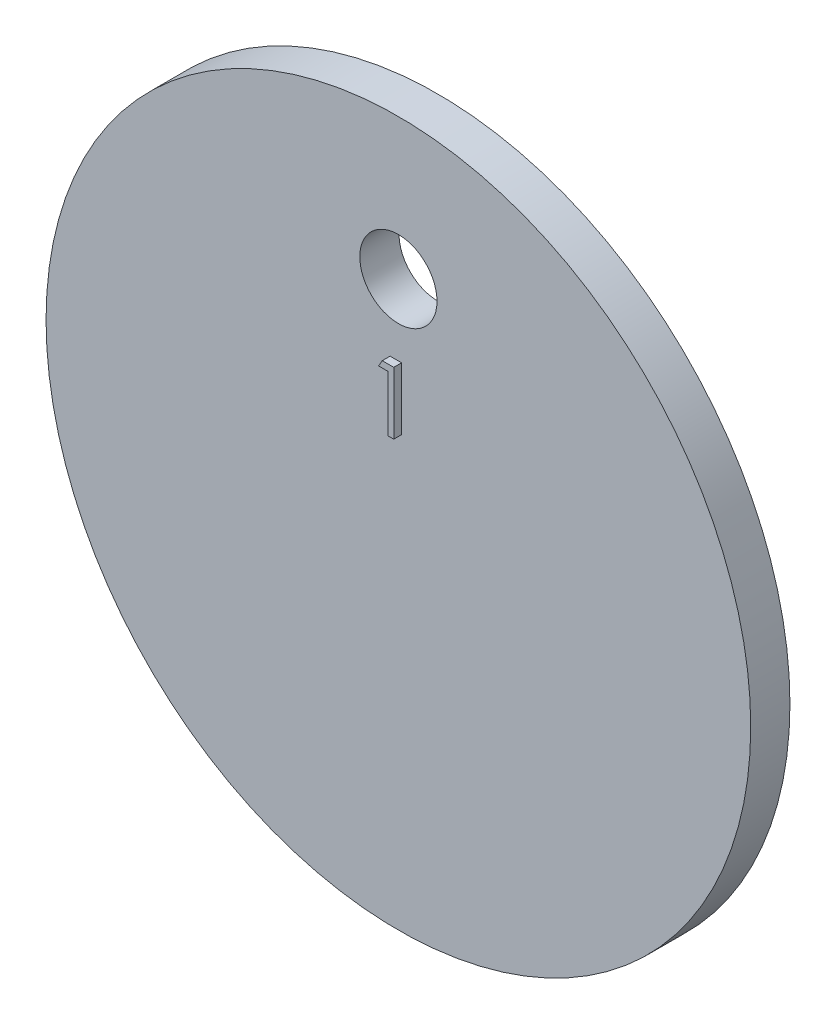
from build123d import *

# Parameters (mm, degrees)
SKIZZE1_R                       = 44.944071705
SKIZZE1_R_2                     = 4.923692712
AUFSATZ_LINEAR_AUSTRAGEN1_DEPTH = 5
AUFSATZ_LINEAR_AUSTRAGEN2_DEPTH = 1


with BuildPart() as part:
    # Skizze1 → Aufsatz-Linear austragen1 (new body)
    with BuildSketch(Plane.XY):
        Circle(SKIZZE1_R)
        with Locations((0, 26.9875)):
            Circle(SKIZZE1_R_2, mode=Mode.SUBTRACT)
    extrude(amount=AUFSATZ_LINEAR_AUSTRAGEN1_DEPTH)

    # Skizze2 → Aufsatz-Linear austragen2 (add)
    with BuildSketch(Plane.XY.offset(5)):
        Polygon((-1.060559395, 17.9375), (0.407051282, 17.9375), (0.407051282, 10), (-0.305288462, 10), (-0.305288462, 17.123397436), (-1.526442308, 17.123397436), align=None)
    extrude(amount=AUFSATZ_LINEAR_AUSTRAGEN2_DEPTH)


solid = part.part
